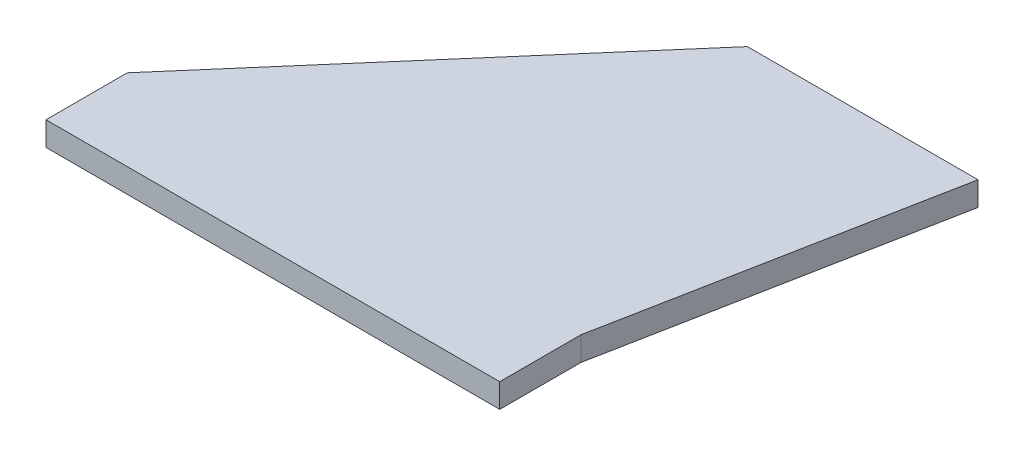
from build123d import *

# Parameters (mm, degrees)
BOSS_EXTRUDE1_DEPTH = 6.35
SKETCH3_W           = 120
SKETCH3_H           = 21.5
BOSS_EXTRUDE2_DEPTH = 6.35


with BuildPart() as part:
    # Sketch1 → Boss-Extrude1 (new body)
    with BuildSketch(Plane(origin=(0, 0, 0), x_dir=(1, 0, 0), z_dir=(0, 1, 0))):
        Polygon((-120, 0), (0, 0), (17, 88), (-44, 88), align=None)
    extrude(amount=BOSS_EXTRUDE1_DEPTH)

    # Sketch3 → Boss-Extrude2 (add)
    with BuildSketch(Plane(origin=(0, 0, 0), x_dir=(1, 0, 0), z_dir=(0, 1, 0))):
        with Locations((-60, -10.75)):
            Rectangle(SKETCH3_W, SKETCH3_H)
    extrude(amount=BOSS_EXTRUDE2_DEPTH)


solid = part.part
